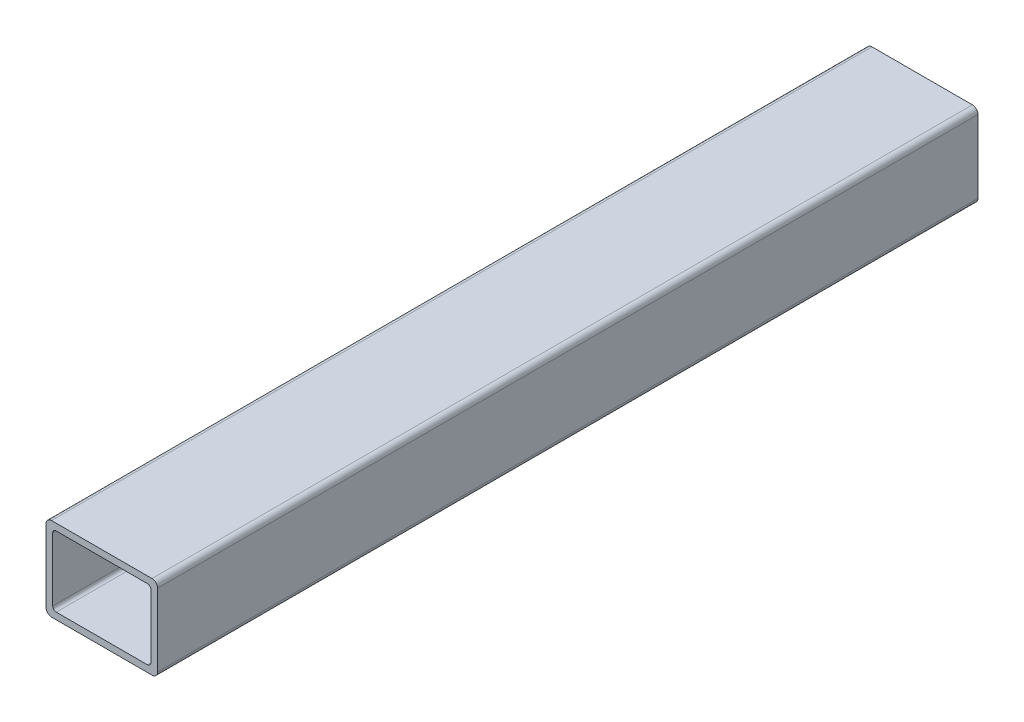
from build123d import *

# Parameters (mm, degrees)
BOSS_EXTRUDE1_DEPTH = 373.61368


with BuildPart() as part:
    # Sketch4 → Boss-Extrude1 (new body)
    with BuildSketch(Plane.XY):
        with BuildLine():
            Line((25.4, -16.51), (25.4, 16.51))
            ThreePointArc((25.4, 16.51), (24.656051224, 18.306051224), (22.86, 19.05))
            Line((22.86, 19.05), (-22.86, 19.05))
            ThreePointArc((-22.86, 19.05), (-24.656051224, 18.306051224), (-25.4, 16.51))
            Line((-25.4, 16.51), (-25.4, -16.51))
            ThreePointArc((-25.4, -16.51), (-24.656051224, -18.306051224), (-22.86, -19.05))
            Line((-22.86, -19.05), (22.86, -19.05))
            ThreePointArc((22.86, -19.05), (24.656051224, -18.306051224), (25.4, -16.51))
        make_face()
        with BuildLine():
            Line((22.352, 14.4018), (22.352, -14.4018))
            ThreePointArc((22.352, -14.4018), (21.883312271, -15.533312271), (20.7518, -16.002))
            Line((20.7518, -16.002), (-20.7518, -16.002))
            ThreePointArc((-20.7518, -16.002), (-21.883312271, -15.533312271), (-22.352, -14.4018))
            Line((-22.352, -14.4018), (-22.352, 14.4018))
            ThreePointArc((-22.352, 14.4018), (-21.883312271, 15.533312271), (-20.7518, 16.002))
            Line((-20.7518, 16.002), (20.7518, 16.002))
            ThreePointArc((20.7518, 16.002), (21.883312271, 15.533312271), (22.352, 14.4018))
        make_face(mode=Mode.SUBTRACT)
    extrude(amount=BOSS_EXTRUDE1_DEPTH)


solid = part.part
